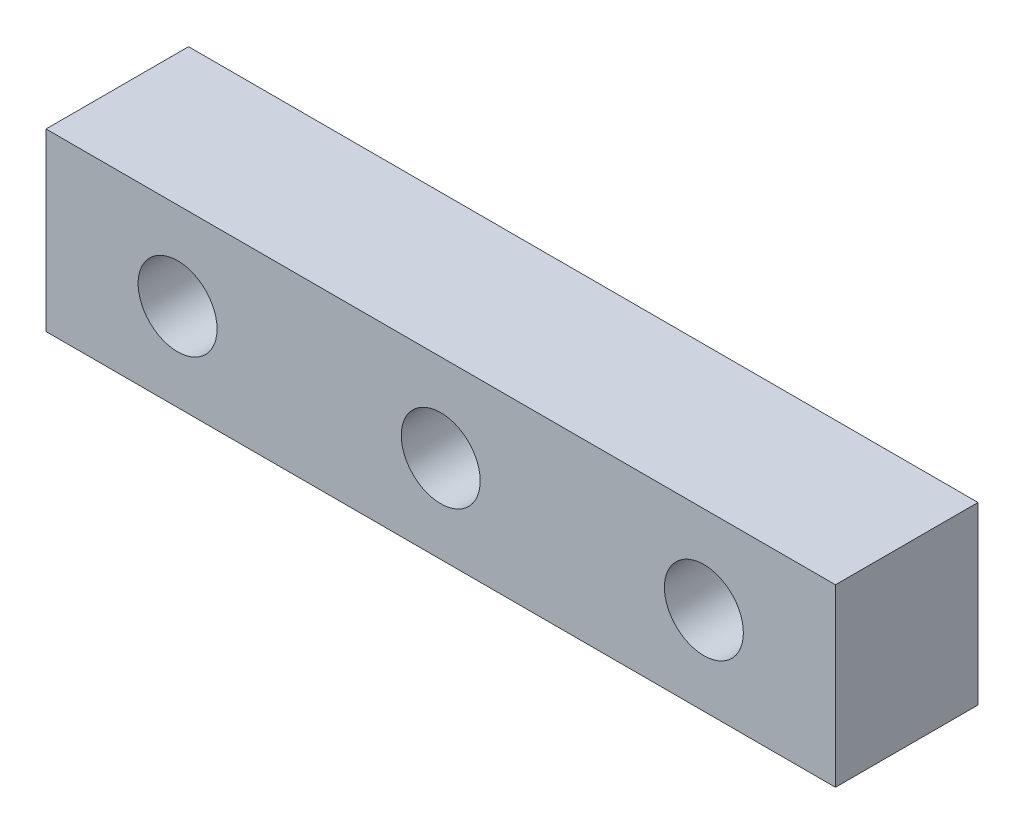
from build123d import *

# Parameters (mm, degrees)
SKETCH_1_W      = 90
SKETCH_1_H      = 20
SKETCH_1_R      = 4.5
EXTRUDE_1_DEPTH = 16.25


with BuildPart() as part:
    # 草图1 → 凸台-拉伸1 (new body)
    with BuildSketch(Plane.XY):
        Rectangle(SKETCH_1_W, SKETCH_1_H)
        with Locations((-30, 0)):
            Circle(SKETCH_1_R, mode=Mode.SUBTRACT)
        Circle(SKETCH_1_R, mode=Mode.SUBTRACT)
        with Locations((30, 0)):
            Circle(SKETCH_1_R, mode=Mode.SUBTRACT)
    extrude(amount=EXTRUDE_1_DEPTH)


solid = part.part
